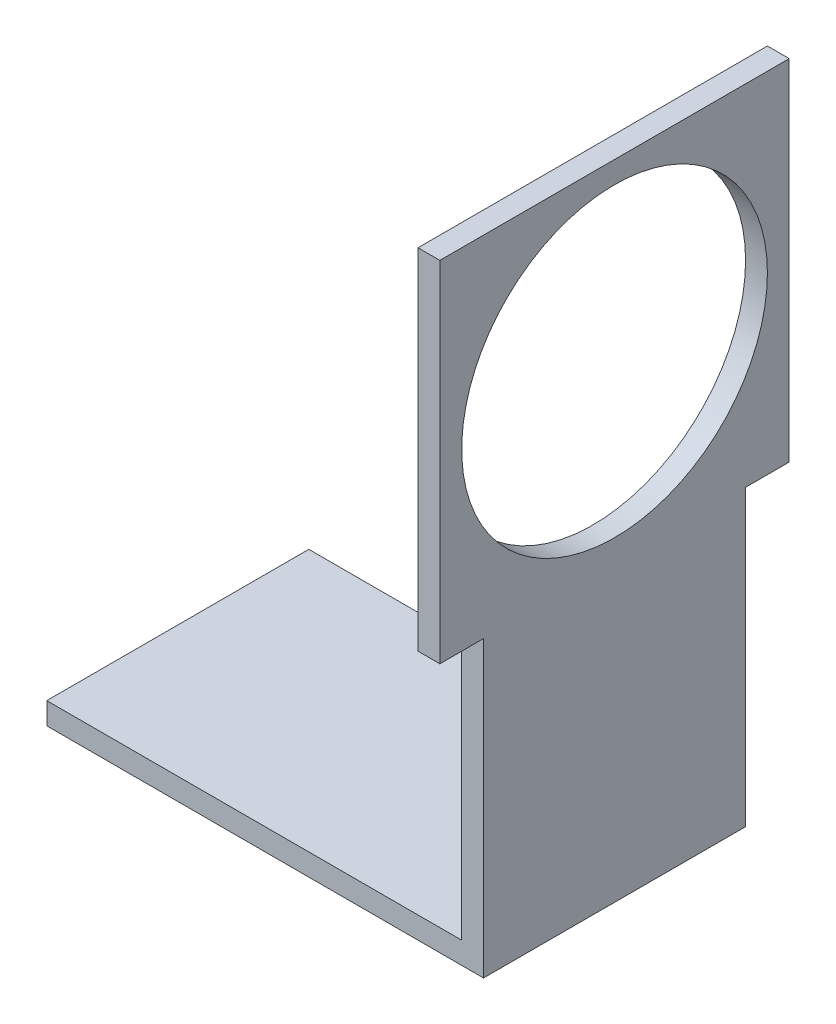
from build123d import *

# Parameters (mm, degrees)
SKETCH1_W           = 100
SKETCH1_H           = 60
BOSS_EXTRUDE1_DEPTH = 5
SKETCH2_W           = 5
SKETCH2_H           = 60
BOSS_EXTRUDE2_DEPTH = 62.3
BOSS_EXTRUDE3_DEPTH = 5
SKETCH5_R           = 35
CUT_EXTRUDE1_DEPTH  = 5


with BuildPart() as part:
    # Sketch1 → Boss-Extrude1 (new body)
    with BuildSketch(Plane(origin=(0, 0, 0), x_dir=(1, 0, 0), z_dir=(0, 1, 0))):
        with Locations((-43.057324841, 0.76433121)):
            Rectangle(SKETCH1_W, SKETCH1_H)
    extrude(amount=BOSS_EXTRUDE1_DEPTH)

    # Sketch2 → Boss-Extrude2 (add)
    with BuildSketch(Plane(origin=(0, 5, 0), x_dir=(1, 0, 0), z_dir=(0, 1, 0))):
        with Locations((4.442675159, 0.76433121)):
            Rectangle(SKETCH2_W, SKETCH2_H)
    extrude(amount=BOSS_EXTRUDE2_DEPTH)

    # Sketch4 → Boss-Extrude3 (add)
    with BuildSketch(Plane(origin=(6.942675159, 0, 0), x_dir=(0, 0, -1), z_dir=(1, 0, 0))):
        Polygon((-29.23566879, 67.3), (40.76433121, 67.3), (40.76433121, 147.3), (-39.23566879, 147.3), (-39.23566879, 67.3), align=None)
    extrude(amount=-BOSS_EXTRUDE3_DEPTH)

    # Sketch5 → Cut-Extrude1 (cut)
    with BuildSketch(Plane(origin=(6.942675159, 0, 0), x_dir=(0, 0, -1), z_dir=(1, 0, 0))):
        with Locations((0.76433121, 107.3)):
            Circle(SKETCH5_R)
    extrude(amount=-CUT_EXTRUDE1_DEPTH, mode=Mode.SUBTRACT)


solid = part.part
